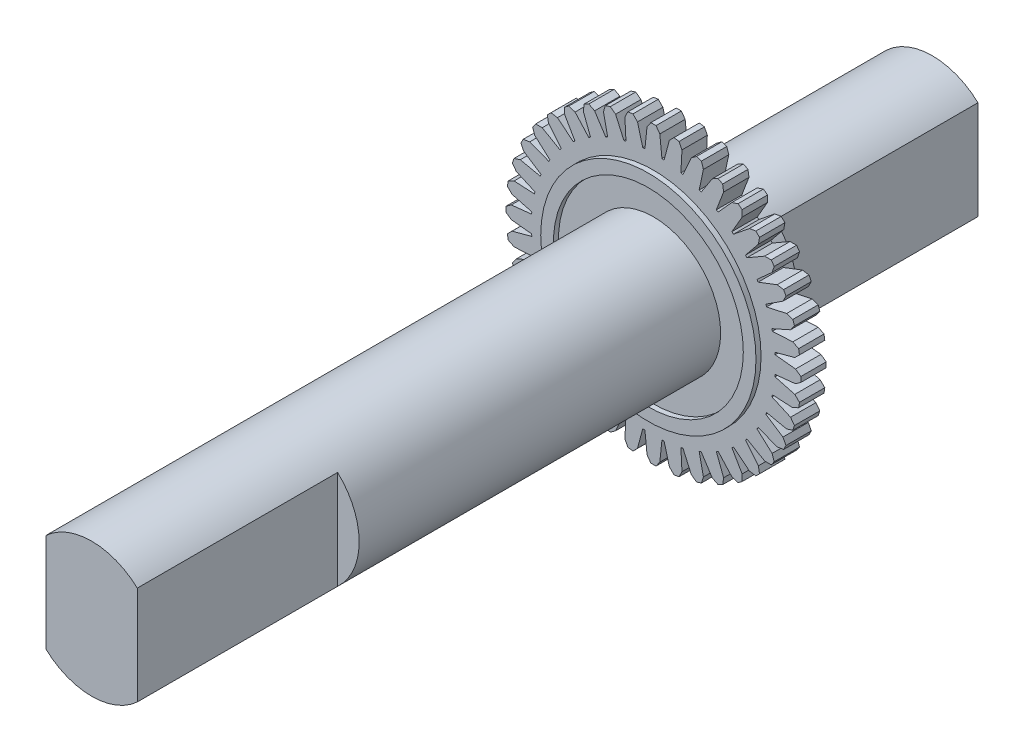
from build123d import *

# Parameters (mm, degrees)
BOSS_EXTRUDE1_DEPTH = 1
SKETCH2_R           = 4.245
SKETCH2_R_2         = 3.745
BOSS_EXTRUDE2_DEPTH = 0.2
SKETCH3_R           = 2.65
BOSS_EXTRUDE3_DEPTH = 22.154843669
SKETCH4_R           = 2.65
BOSS_EXTRUDE4_DEPTH = 2
CUT_EXTRUDE2_DEPTH  = 17
BOSS_EXTRUDE5_DEPTH = 8
BOSS_EXTRUDE6_DEPTH = 9.1


with BuildPart() as part:
    # Sketch1 → Boss-Extrude1 (new body)
    with BuildSketch(Plane.XY):
        with BuildLine():
            Line((1.009764153, 5.726657084), (1.125066167, 5.495777362))
            Line((1.125066167, 5.495777362), (1.083139327, 4.691591862))
            ThreePointArc((1.083139327, 4.691591862), (1.124039427, 4.681961167), (1.164853927, 4.671973922))
            Line((1.164853927, 4.671973922), (1.492589417, 5.407542837))
            Line((1.492589417, 5.407542837), (1.700141463, 5.560912156))
            ThreePointArc((1.700141463, 5.560912156), (1.796933822, 5.530393642), (1.893178818, 5.498190517))
            Line((1.893178818, 5.498190517), (1.970943727, 5.2521161))
            Line((1.970943727, 5.2521161), (1.803730747, 4.46439026))
            ThreePointArc((1.803730747, 4.46439026), (1.842620727, 4.448479949), (1.881370384, 4.432230869))
            Line((1.881370384, 4.432230869), (2.320139235, 5.107474584))
            Line((2.320139235, 5.107474584), (2.549128219, 5.226487379))
            ThreePointArc((2.549128219, 5.226487379), (2.639954756, 5.181202938), (2.729977138, 5.134340252))
            Line((2.729977138, 5.134340252), (2.768290111, 4.879130307))
            Line((2.768290111, 4.879130307), (2.479908331, 4.127260553))
            ThreePointArc((2.479908331, 4.127260553), (2.515830589, 4.105462391), (2.551561257, 4.083351583))
            Line((2.551561257, 4.083351583), (3.090559525, 4.681643357))
            Line((3.090559525, 4.681643357), (3.335346977, 4.763369138))
            ThreePointArc((3.335346977, 4.763369138), (3.417971242, 4.704433822), (3.49955436, 4.644065491))
            Line((3.49955436, 4.644065491), (3.497472006, 4.386004134))
            Line((3.497472006, 4.386004134), (3.095022341, 3.688503994))
            ThreePointArc((3.095022341, 3.688503994), (3.127092353, 3.661354724), (3.158924225, 3.633926629))
            Line((3.158924225, 3.633926629), (3.784879983, 4.140534532))
            Line((3.784879983, 4.140534532), (4.039438424, 4.182960939))
            ThreePointArc((4.039438424, 4.182960939), (4.111825933, 4.111825933), (4.182960939, 4.039438424))
            Line((4.182960939, 4.039438424), (4.140534532, 3.784879983))
            Line((4.140534532, 3.784879983), (3.633926629, 3.158924225))
            ThreePointArc((3.633926629, 3.158924225), (3.661354724, 3.127092353), (3.688503994, 3.095022341))
            Line((3.688503994, 3.095022341), (4.386004134, 3.497472006))
            Line((4.386004134, 3.497472006), (4.644065491, 3.49955436))
            ThreePointArc((4.644065491, 3.49955436), (4.704433822, 3.417971242), (4.763369138, 3.335346977))
            Line((4.763369138, 3.335346977), (4.681643357, 3.090559525))
            Line((4.681643357, 3.090559525), (4.083351583, 2.551561257))
            ThreePointArc((4.083351583, 2.551561257), (4.105462391, 2.515830589), (4.127260553, 2.479908331))
            Line((4.127260553, 2.479908331), (4.879130307, 2.768290111))
            Line((4.879130307, 2.768290111), (5.134340252, 2.729977138))
            ThreePointArc((5.134340252, 2.729977138), (5.181202938, 2.639954756), (5.226487379, 2.549128219))
            Line((5.226487379, 2.549128219), (5.107474584, 2.320139235))
            Line((5.107474584, 2.320139235), (4.432230869, 1.881370384))
            ThreePointArc((4.432230869, 1.881370384), (4.448479949, 1.842620727), (4.46439026, 1.803730747))
            Line((4.46439026, 1.803730747), (5.2521161, 1.970943727))
            Line((5.2521161, 1.970943727), (5.498190517, 1.893178818))
            ThreePointArc((5.498190517, 1.893178818), (5.530393642, 1.796933822), (5.560912156, 1.700141463))
            Line((5.560912156, 1.700141463), (5.407542837, 1.492589417))
            Line((5.407542837, 1.492589417), (4.671973922, 1.164853927))
            ThreePointArc((4.671973922, 1.164853927), (4.681961167, 1.124039427), (4.691591862, 1.083139327))
            Line((4.691591862, 1.083139327), (5.495777362, 1.125066167))
            Line((5.495777362, 1.125066167), (5.726657084, 1.009764153))
            ThreePointArc((5.726657084, 1.009764153), (5.743407701, 0.909666414), (5.75840882, 0.809291582))
            Line((5.75840882, 0.809291582), (5.574459438, 0.628287093))
            Line((5.574459438, 0.628287093), (4.796677471, 0.419654901))
            ThreePointArc((4.796677471, 0.419654901), (4.800156962, 0.377780546), (4.803270902, 0.335877421))
            Line((4.803270902, 0.335877421), (5.604114347, 0.251485743))
            Line((5.604114347, 0.251485743), (5.814114347, 0.101485743))
            ThreePointArc((5.814114347, 0.101485743), (5.815, 0), (5.814114347, -0.101485743))
            Line((5.814114347, -0.101485743), (5.604114347, -0.251485743))
            Line((5.604114347, -0.251485743), (4.803270902, -0.335877421))
            ThreePointArc((4.803270902, -0.335877421), (4.800156962, -0.377780546), (4.796677471, -0.419654901))
            Line((4.796677471, -0.419654901), (5.574459438, -0.628287093))
            Line((5.574459438, -0.628287093), (5.75840882, -0.809291582))
            ThreePointArc((5.75840882, -0.809291582), (5.743407701, -0.909666414), (5.726657084, -1.009764153))
            Line((5.726657084, -1.009764153), (5.495777362, -1.125066167))
            Line((5.495777362, -1.125066167), (4.691591862, -1.083139327))
            ThreePointArc((4.691591862, -1.083139327), (4.681961167, -1.124039427), (4.671973922, -1.164853927))
            Line((4.671973922, -1.164853927), (5.407542837, -1.492589417))
            Line((5.407542837, -1.492589417), (5.560912156, -1.700141463))
            ThreePointArc((5.560912156, -1.700141463), (5.530393642, -1.796933822), (5.498190517, -1.893178818))
            Line((5.498190517, -1.893178818), (5.2521161, -1.970943727))
            Line((5.2521161, -1.970943727), (4.46439026, -1.803730747))
            ThreePointArc((4.46439026, -1.803730747), (4.448479949, -1.842620727), (4.432230869, -1.881370384))
            Line((4.432230869, -1.881370384), (5.107474584, -2.320139235))
            Line((5.107474584, -2.320139235), (5.226487379, -2.549128219))
            ThreePointArc((5.226487379, -2.549128219), (5.181202938, -2.639954756), (5.134340252, -2.729977138))
            Line((5.134340252, -2.729977138), (4.879130307, -2.768290111))
            Line((4.879130307, -2.768290111), (4.127260553, -2.479908331))
            ThreePointArc((4.127260553, -2.479908331), (4.105462391, -2.515830589), (4.083351583, -2.551561257))
            Line((4.083351583, -2.551561257), (4.681643357, -3.090559525))
            Line((4.681643357, -3.090559525), (4.763369138, -3.335346977))
            ThreePointArc((4.763369138, -3.335346977), (4.704433822, -3.417971242), (4.644065491, -3.49955436))
            Line((4.644065491, -3.49955436), (4.386004134, -3.497472006))
            Line((4.386004134, -3.497472006), (3.688503994, -3.095022341))
            ThreePointArc((3.688503994, -3.095022341), (3.661354724, -3.127092353), (3.633926629, -3.158924225))
            Line((3.633926629, -3.158924225), (4.140534532, -3.784879983))
            Line((4.140534532, -3.784879983), (4.182960939, -4.039438424))
            ThreePointArc((4.182960939, -4.039438424), (4.111825933, -4.111825933), (4.039438424, -4.182960939))
            Line((4.039438424, -4.182960939), (3.784879983, -4.140534532))
            Line((3.784879983, -4.140534532), (3.158924225, -3.633926629))
            ThreePointArc((3.158924225, -3.633926629), (3.127092353, -3.661354724), (3.095022341, -3.688503994))
            Line((3.095022341, -3.688503994), (3.497472006, -4.386004134))
            Line((3.497472006, -4.386004134), (3.49955436, -4.644065491))
            ThreePointArc((3.49955436, -4.644065491), (3.417971242, -4.704433822), (3.335346977, -4.763369138))
            Line((3.335346977, -4.763369138), (3.090559525, -4.681643357))
            Line((3.090559525, -4.681643357), (2.551561257, -4.083351583))
            ThreePointArc((2.551561257, -4.083351583), (2.515830589, -4.105462391), (2.479908331, -4.127260553))
            Line((2.479908331, -4.127260553), (2.768290111, -4.879130307))
            Line((2.768290111, -4.879130307), (2.729977138, -5.134340252))
            ThreePointArc((2.729977138, -5.134340252), (2.639954756, -5.181202938), (2.549128219, -5.226487379))
            Line((2.549128219, -5.226487379), (2.320139235, -5.107474584))
            Line((2.320139235, -5.107474584), (1.881370384, -4.432230869))
            ThreePointArc((1.881370384, -4.432230869), (1.842620727, -4.448479949), (1.803730747, -4.46439026))
            Line((1.803730747, -4.46439026), (1.970943727, -5.2521161))
            Line((1.970943727, -5.2521161), (1.893178818, -5.498190517))
            ThreePointArc((1.893178818, -5.498190517), (1.796933822, -5.530393642), (1.700141463, -5.560912156))
            Line((1.700141463, -5.560912156), (1.492589417, -5.407542837))
            Line((1.492589417, -5.407542837), (1.164853927, -4.671973922))
            ThreePointArc((1.164853927, -4.671973922), (1.124039427, -4.681961167), (1.083139327, -4.691591862))
            Line((1.083139327, -4.691591862), (1.125066167, -5.495777362))
            Line((1.125066167, -5.495777362), (1.009764153, -5.726657084))
            ThreePointArc((1.009764153, -5.726657084), (0.909666414, -5.743407701), (0.809291582, -5.75840882))
            Line((0.809291582, -5.75840882), (0.628287093, -5.574459438))
            Line((0.628287093, -5.574459438), (0.419654901, -4.796677471))
            ThreePointArc((0.419654901, -4.796677471), (0.377780546, -4.800156962), (0.335877421, -4.803270902))
            Line((0.335877421, -4.803270902), (0.251485743, -5.604114347))
            Line((0.251485743, -5.604114347), (0.101485743, -5.814114347))
            ThreePointArc((0.101485743, -5.814114347), (0, -5.815), (-0.101485743, -5.814114347))
            Line((-0.101485743, -5.814114347), (-0.251485743, -5.604114347))
            Line((-0.251485743, -5.604114347), (-0.335877421, -4.803270902))
            ThreePointArc((-0.335877421, -4.803270902), (-0.377780546, -4.800156962), (-0.419654901, -4.796677471))
            Line((-0.419654901, -4.796677471), (-0.628287093, -5.574459438))
            Line((-0.628287093, -5.574459438), (-0.809291582, -5.75840882))
            ThreePointArc((-0.809291582, -5.75840882), (-0.909666414, -5.743407701), (-1.009764153, -5.726657084))
            Line((-1.009764153, -5.726657084), (-1.125066167, -5.495777362))
            Line((-1.125066167, -5.495777362), (-1.083139327, -4.691591862))
            ThreePointArc((-1.083139327, -4.691591862), (-1.124039427, -4.681961167), (-1.164853927, -4.671973922))
            Line((-1.164853927, -4.671973922), (-1.492589417, -5.407542837))
            Line((-1.492589417, -5.407542837), (-1.700141463, -5.560912156))
            ThreePointArc((-1.700141463, -5.560912156), (-1.796933822, -5.530393642), (-1.893178818, -5.498190517))
            Line((-1.893178818, -5.498190517), (-1.970943727, -5.2521161))
            Line((-1.970943727, -5.2521161), (-1.803730747, -4.46439026))
            ThreePointArc((-1.803730747, -4.46439026), (-1.842620727, -4.448479949), (-1.881370384, -4.432230869))
            Line((-1.881370384, -4.432230869), (-2.320139235, -5.107474584))
            Line((-2.320139235, -5.107474584), (-2.549128219, -5.226487379))
            ThreePointArc((-2.549128219, -5.226487379), (-2.639954756, -5.181202938), (-2.729977138, -5.134340252))
            Line((-2.729977138, -5.134340252), (-2.768290111, -4.879130307))
            Line((-2.768290111, -4.879130307), (-2.479908331, -4.127260553))
            ThreePointArc((-2.479908331, -4.127260553), (-2.515830589, -4.105462391), (-2.551561257, -4.083351583))
            Line((-2.551561257, -4.083351583), (-3.090559525, -4.681643357))
            Line((-3.090559525, -4.681643357), (-3.335346977, -4.763369138))
            ThreePointArc((-3.335346977, -4.763369138), (-3.417971242, -4.704433822), (-3.49955436, -4.644065491))
            Line((-3.49955436, -4.644065491), (-3.497472006, -4.386004134))
            Line((-3.497472006, -4.386004134), (-3.095022341, -3.688503994))
            ThreePointArc((-3.095022341, -3.688503994), (-3.127092353, -3.661354724), (-3.158924225, -3.633926629))
            Line((-3.158924225, -3.633926629), (-3.784879983, -4.140534532))
            Line((-3.784879983, -4.140534532), (-4.039438424, -4.182960939))
            ThreePointArc((-4.039438424, -4.182960939), (-4.111825933, -4.111825933), (-4.182960939, -4.039438424))
            Line((-4.182960939, -4.039438424), (-4.140534532, -3.784879983))
            Line((-4.140534532, -3.784879983), (-3.633926629, -3.158924225))
            ThreePointArc((-3.633926629, -3.158924225), (-3.661354724, -3.127092353), (-3.688503994, -3.095022341))
            Line((-3.688503994, -3.095022341), (-4.386004134, -3.497472006))
            Line((-4.386004134, -3.497472006), (-4.644065491, -3.49955436))
            ThreePointArc((-4.644065491, -3.49955436), (-4.704433822, -3.417971242), (-4.763369138, -3.335346977))
            Line((-4.763369138, -3.335346977), (-4.681643357, -3.090559525))
            Line((-4.681643357, -3.090559525), (-4.083351583, -2.551561257))
            ThreePointArc((-4.083351583, -2.551561257), (-4.105462391, -2.515830589), (-4.127260553, -2.479908331))
            Line((-4.127260553, -2.479908331), (-4.879130307, -2.768290111))
            Line((-4.879130307, -2.768290111), (-5.134340252, -2.729977138))
            ThreePointArc((-5.134340252, -2.729977138), (-5.181202938, -2.639954756), (-5.226487379, -2.549128219))
            Line((-5.226487379, -2.549128219), (-5.107474584, -2.320139235))
            Line((-5.107474584, -2.320139235), (-4.432230869, -1.881370384))
            ThreePointArc((-4.432230869, -1.881370384), (-4.448479949, -1.842620727), (-4.46439026, -1.803730747))
            Line((-4.46439026, -1.803730747), (-5.2521161, -1.970943727))
            Line((-5.2521161, -1.970943727), (-5.498190517, -1.893178818))
            ThreePointArc((-5.498190517, -1.893178818), (-5.530393642, -1.796933822), (-5.560912156, -1.700141463))
            Line((-5.560912156, -1.700141463), (-5.407542837, -1.492589417))
            Line((-5.407542837, -1.492589417), (-4.671973922, -1.164853927))
            ThreePointArc((-4.671973922, -1.164853927), (-4.681961167, -1.124039427), (-4.691591862, -1.083139327))
            Line((-4.691591862, -1.083139327), (-5.495777362, -1.125066167))
            Line((-5.495777362, -1.125066167), (-5.726657084, -1.009764153))
            ThreePointArc((-5.726657084, -1.009764153), (-5.743407701, -0.909666414), (-5.75840882, -0.809291582))
            Line((-5.75840882, -0.809291582), (-5.574459438, -0.628287093))
            Line((-5.574459438, -0.628287093), (-4.796677471, -0.419654901))
            ThreePointArc((-4.796677471, -0.419654901), (-4.800156962, -0.377780546), (-4.803270902, -0.335877421))
            Line((-4.803270902, -0.335877421), (-5.604114347, -0.251485743))
            Line((-5.604114347, -0.251485743), (-5.814114347, -0.101485743))
            ThreePointArc((-5.814114347, -0.101485743), (-5.815, 0), (-5.814114347, 0.101485743))
            Line((-5.814114347, 0.101485743), (-5.604114347, 0.251485743))
            Line((-5.604114347, 0.251485743), (-4.803270902, 0.335877421))
            ThreePointArc((-4.803270902, 0.335877421), (-4.800156962, 0.377780546), (-4.796677471, 0.419654901))
            Line((-4.796677471, 0.419654901), (-5.574459438, 0.628287093))
            Line((-5.574459438, 0.628287093), (-5.75840882, 0.809291582))
            ThreePointArc((-5.75840882, 0.809291582), (-5.743407701, 0.909666414), (-5.726657084, 1.009764153))
            Line((-5.726657084, 1.009764153), (-5.495777362, 1.125066167))
            Line((-5.495777362, 1.125066167), (-4.691591862, 1.083139327))
            ThreePointArc((-4.691591862, 1.083139327), (-4.681961167, 1.124039427), (-4.671973922, 1.164853927))
            Line((-4.671973922, 1.164853927), (-5.407542837, 1.492589417))
            Line((-5.407542837, 1.492589417), (-5.560912156, 1.700141463))
            ThreePointArc((-5.560912156, 1.700141463), (-5.530393642, 1.796933822), (-5.498190517, 1.893178818))
            Line((-5.498190517, 1.893178818), (-5.2521161, 1.970943727))
            Line((-5.2521161, 1.970943727), (-4.46439026, 1.803730747))
            ThreePointArc((-4.46439026, 1.803730747), (-4.448479949, 1.842620727), (-4.432230869, 1.881370384))
            Line((-4.432230869, 1.881370384), (-5.107474584, 2.320139235))
            Line((-5.107474584, 2.320139235), (-5.226487379, 2.549128219))
            ThreePointArc((-5.226487379, 2.549128219), (-5.181202938, 2.639954756), (-5.134340252, 2.729977138))
            Line((-5.134340252, 2.729977138), (-4.879130307, 2.768290111))
            Line((-4.879130307, 2.768290111), (-4.127260553, 2.479908331))
            ThreePointArc((-4.127260553, 2.479908331), (-4.105462391, 2.515830589), (-4.083351583, 2.551561257))
            Line((-4.083351583, 2.551561257), (-4.681643357, 3.090559525))
            Line((-4.681643357, 3.090559525), (-4.763369138, 3.335346977))
            ThreePointArc((-4.763369138, 3.335346977), (-4.704433822, 3.417971242), (-4.644065491, 3.49955436))
            Line((-4.644065491, 3.49955436), (-4.386004134, 3.497472006))
            Line((-4.386004134, 3.497472006), (-3.688503994, 3.095022341))
            ThreePointArc((-3.688503994, 3.095022341), (-3.661354724, 3.127092353), (-3.633926629, 3.158924225))
            Line((-3.633926629, 3.158924225), (-4.140534532, 3.784879983))
            Line((-4.140534532, 3.784879983), (-4.182960939, 4.039438424))
            ThreePointArc((-4.182960939, 4.039438424), (-4.111825933, 4.111825933), (-4.039438424, 4.182960939))
            Line((-4.039438424, 4.182960939), (-3.784879983, 4.140534532))
            Line((-3.784879983, 4.140534532), (-3.158924225, 3.633926629))
            ThreePointArc((-3.158924225, 3.633926629), (-3.127092353, 3.661354724), (-3.095022341, 3.688503994))
            Line((-3.095022341, 3.688503994), (-3.497472006, 4.386004134))
            Line((-3.497472006, 4.386004134), (-3.49955436, 4.644065491))
            ThreePointArc((-3.49955436, 4.644065491), (-3.417971242, 4.704433822), (-3.335346977, 4.763369138))
            Line((-3.335346977, 4.763369138), (-3.090559525, 4.681643357))
            Line((-3.090559525, 4.681643357), (-2.551561257, 4.083351583))
            ThreePointArc((-2.551561257, 4.083351583), (-2.515830589, 4.105462391), (-2.479908331, 4.127260553))
            Line((-2.479908331, 4.127260553), (-2.768290111, 4.879130307))
            Line((-2.768290111, 4.879130307), (-2.729977138, 5.134340252))
            ThreePointArc((-2.729977138, 5.134340252), (-2.639954756, 5.181202938), (-2.549128219, 5.226487379))
            Line((-2.549128219, 5.226487379), (-2.320139235, 5.107474584))
            Line((-2.320139235, 5.107474584), (-1.881370384, 4.432230869))
            ThreePointArc((-1.881370384, 4.432230869), (-1.842620727, 4.448479949), (-1.803730747, 4.46439026))
            Line((-1.803730747, 4.46439026), (-1.970943727, 5.2521161))
            Line((-1.970943727, 5.2521161), (-1.893178818, 5.498190517))
            ThreePointArc((-1.893178818, 5.498190517), (-1.796933822, 5.530393642), (-1.700141463, 5.560912156))
            Line((-1.700141463, 5.560912156), (-1.492589417, 5.407542837))
            Line((-1.492589417, 5.407542837), (-1.164853927, 4.671973922))
            ThreePointArc((-1.164853927, 4.671973922), (-1.124039427, 4.681961167), (-1.083139327, 4.691591862))
            Line((-1.083139327, 4.691591862), (-1.125066167, 5.495777362))
            Line((-1.125066167, 5.495777362), (-1.009764153, 5.726657084))
            ThreePointArc((-1.009764153, 5.726657084), (-0.909666414, 5.743407701), (-0.809291582, 5.75840882))
            Line((-0.809291582, 5.75840882), (-0.628287093, 5.574459438))
            Line((-0.628287093, 5.574459438), (-0.419654901, 4.796677471))
            ThreePointArc((-0.419654901, 4.796677471), (-0.377780546, 4.800156962), (-0.335877421, 4.803270902))
            Line((-0.335877421, 4.803270902), (-0.251485743, 5.604114347))
            Line((-0.251485743, 5.604114347), (-0.101485743, 5.814114347))
            ThreePointArc((-0.101485743, 5.814114347), (0, 5.815), (0.101485743, 5.814114347))
            Line((0.101485743, 5.814114347), (0.251485743, 5.604114347))
            Line((0.251485743, 5.604114347), (0.335877421, 4.803270902))
            ThreePointArc((0.335877421, 4.803270902), (0.377780546, 4.800156962), (0.419654901, 4.796677471))
            Line((0.419654901, 4.796677471), (0.628287093, 5.574459438))
            Line((0.628287093, 5.574459438), (0.809291582, 5.75840882))
            ThreePointArc((0.809291582, 5.75840882), (0.909666414, 5.743407701), (1.009764153, 5.726657084))
        make_face()
    extrude(amount=BOSS_EXTRUDE1_DEPTH)

    # Sketch2 → Boss-Extrude2 (add)
    with BuildSketch(Plane.XY.offset(1)):
        Circle(SKETCH2_R)
        Circle(SKETCH2_R_2, mode=Mode.SUBTRACT)
    extrude(amount=BOSS_EXTRUDE2_DEPTH)

    # Sketch3 → Boss-Extrude3 (add)
    with BuildSketch(Plane.XY.offset(1)):
        with Locations(Location((0, 0, 0), (0, 0, 270))):
            Circle(SKETCH3_R)
    extrude(amount=BOSS_EXTRUDE3_DEPTH)

    # Sketch4 → Boss-Extrude4 (add)
    with BuildSketch(Plane(origin=(0, 0, 0), x_dir=(-1, 0, 0), z_dir=(0, 0, -1))):
        with Locations(Location((0, 0, 0), (0, 0, 270))):
            Circle(SKETCH4_R)
    extrude(amount=BOSS_EXTRUDE4_DEPTH)

    # Sketch6 → Cut-Extrude2 (cut)
    with BuildSketch(Plane.XY.offset(23.154843669)):
        Polygon((-1.8, 2.795), (-3.445985664, 0.713949615), (-3.204298788, -1.200954095), (-1.8, -2.795), align=None)
        Polygon((1.8, -2.795), (1.8, 4.061135854), (3.633332732, 1.980085468), (3.328151287, -0.959267219), align=None)
    extrude(amount=-CUT_EXTRUDE2_DEPTH, mode=Mode.SUBTRACT)

    # Sketch7 → Boss-Extrude5 (add)
    with BuildSketch(Plane(origin=(0, 0, -2), x_dir=(-1, 0, 0), z_dir=(0, 0, -1))):
        with BuildLine():
            Line((1.8, -1.944865034), (1.8, 1.944865034))
            ThreePointArc((1.8, 1.944865034), (0, 2.65), (-1.8, 1.944865034))
            Line((-1.8, 1.944865034), (-1.8, -1.944865034))
            ThreePointArc((-1.8, -1.944865034), (0, -2.65), (1.8, -1.944865034))
        make_face()
    extrude(amount=BOSS_EXTRUDE5_DEPTH)

    # Sketch8 → Boss-Extrude6 (add)
    with BuildSketch(Plane.XY.offset(6.154843669)):
        with BuildLine():
            Line((-1.8, -1.944865034), (-1.8, 1.944865034))
            ThreePointArc((-1.8, 1.944865034), (-2.65, 0), (-1.8, -1.944865034))
        make_face()
        with BuildLine():
            Line((1.8, 1.944865034), (1.8, -1.944865034))
            ThreePointArc((1.8, -1.944865034), (2.65, 0), (1.8, 1.944865034))
        make_face()
    extrude(amount=BOSS_EXTRUDE6_DEPTH)


solid = part.part
